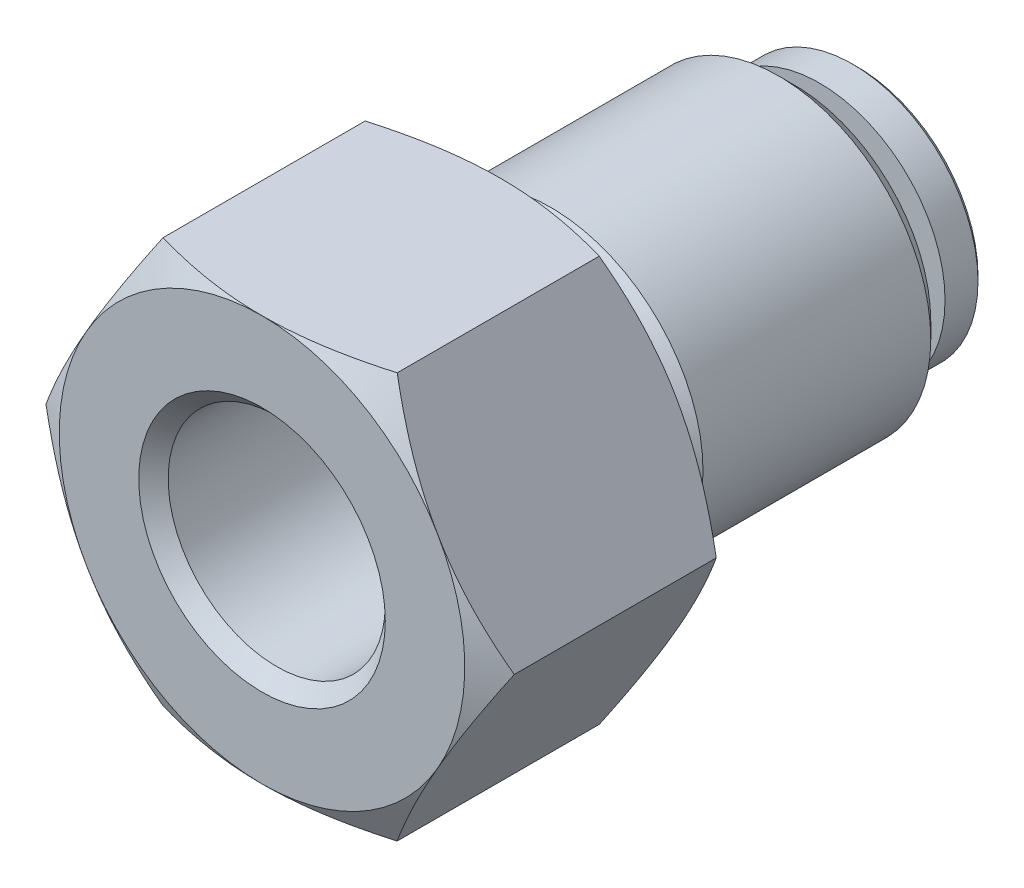
from build123d import *

# Parameters (mm, degrees)
SKETCH2_W          = 32
SKETCH2_H          = 32
CUT_EXTRUDE1_DEPTH = 9.4


with BuildPart() as part:
    # Sketch1 → Revolve1 (revolve)
    with BuildSketch(Plane(origin=(0, 0, 0), x_dir=(1, 0, 0), z_dir=(0, 1, 0))):
        Polygon((0, 0), (-8, 0), (-9.6, 0.923760431), (-9.6, 8.476239569), (-8, 9.4), (-5, 9.4), (-5, 10.4), (-6, 11.4), (-6, 20.3865), (-5.3865, 21), (-3.3, 21), (-3.3, 21.2), (-3, 21.2), (-3, 21.8), (-3.2, 22), (-4.95, 22), (-4.95, 23.3), (-4.75, 23.5), (0, 23.5), align=None)
    revolve(axis=Axis((0, 0, -23.5), (0, 0, 1)))

    # Sketch2 → Cut-Extrude1 (cut)
    with BuildSketch(Plane.XY):
        Rectangle(SKETCH2_W, SKETCH2_H)
        Polygon((-9.237604307, 0), (-4.618802154, -8), (4.618802154, -8), (9.237604307, 0), (4.618802154, 8), (-4.618802154, 8), align=None, mode=Mode.SUBTRACT)
    extrude(amount=-CUT_EXTRUDE1_DEPTH, mode=Mode.SUBTRACT)

    # Sketch3 → Cut-Revolve1 (revolve, cut)
    with BuildSketch(Plane(origin=(0, 0, 0), x_dir=(0, 0, -1), z_dir=(1, 0, 0))):
        Polygon((0, 0), (0, 4.864), (0.581, 4.283), (8.4, 4.283), (8.4, 1.5), (10, 1.5), (10.5, 2), (23.2, 2), (23.5, 2.3), (23.5, 0), align=None)
    revolve(axis=Axis((0, 0, -23.5), (0, 0, 1)), mode=Mode.SUBTRACT)


solid = part.part
